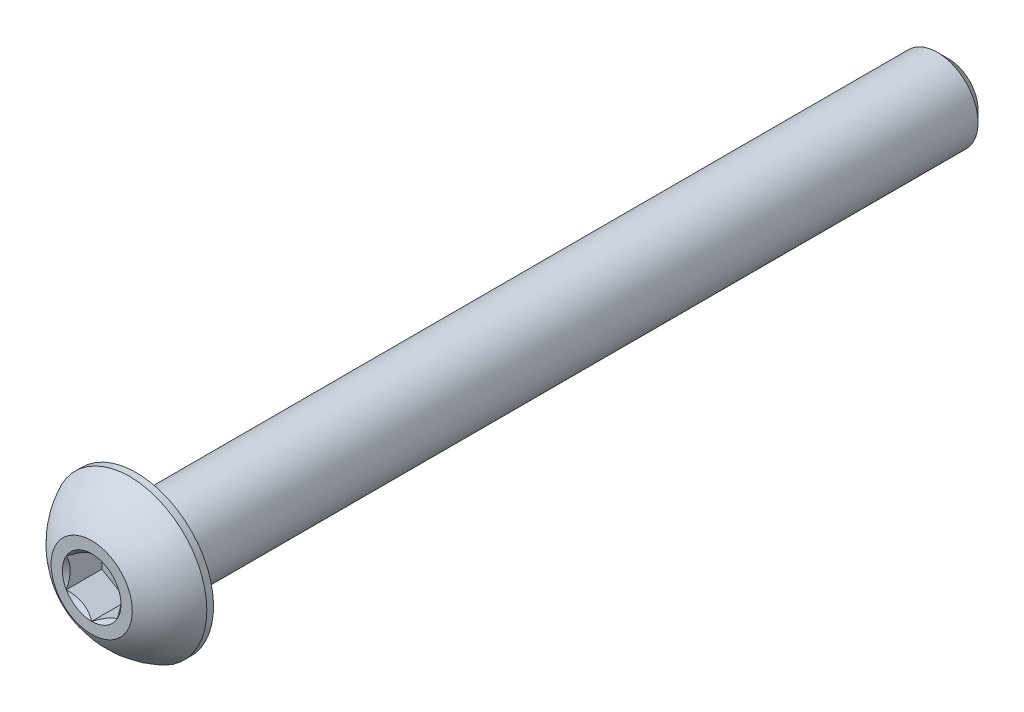
from build123d import *

# Parameters (mm, degrees)
CUT_EXTRUDE1_DEPTH = 1.75


with BuildPart() as part:
    # Sketch2 → Revolve1 (revolve)
    with BuildSketch(Plane(origin=(0, 0, 0), x_dir=(0, 0, -1), z_dir=(1, 0, 0)), mode=Mode.PRIVATE) as revolve1_sk:
        with BuildLine():
            Line((-21.1, 0), (21.1, 0))
            Line((21.1, 0), (21.1, 1.44))
            Line((21.1, 1.44), (20.54, 2))
            Line((20.54, 2), (-18.9, 2))
            Line((-18.9, 2), (-18.9, 3.8))
            Line((-18.9, 3.8), (-19.23, 3.8))
            ThreePointArc((-19.23, 3.8), (-20.306499853, 3.047002626), (-21.1, 2))
            Line((-21.1, 2), (-21.1, 0))
        make_face()
    revolve(revolve1_sk.sketch.rotate(Axis((0, 0, 21.1), (0, 0, -1)), 180), axis=Axis((0, 0, 21.1), (0, 0, -1)))

    # Sketch3 → Cut-Extrude1 (cut)
    with BuildSketch(Plane.XY.offset(21.1)):
        Polygon((0, 1.443375673), (-1.25, 0.721687836), (-1.25, -0.721687836), (0, -1.443375673), (1.25, -0.721687836), (1.25, 0.721687836), align=None)
    extrude(amount=-CUT_EXTRUDE1_DEPTH, mode=Mode.SUBTRACT)

    # Cut-Extrude2 cone 1 section (through the dimple's axis) → Cut-Extrude2 (revolve, cut)
    with BuildSketch(Plane(origin=(0, 0, 21.1), x_dir=(0, -1, 0), z_dir=(1, 0, 0))):
        Polygon((0, 0), (1.443375673, 0), (0, 1.443375673), align=None)
    revolve(axis=Axis((0, 0, 21.1), (0, 0, -1)), mode=Mode.SUBTRACT)


solid = part.part
